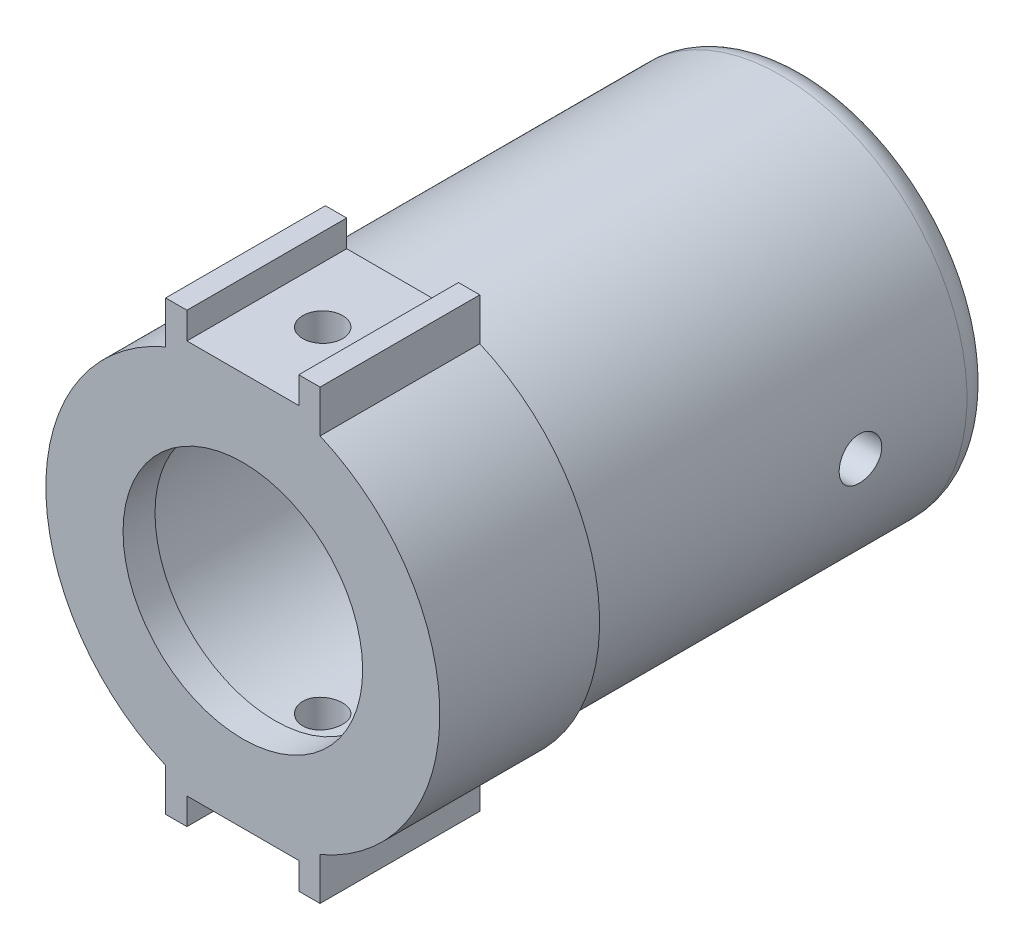
from build123d import *

# Parameters (mm, degrees)
SKETCH10_R              = 7.4
SKETCH10_R_2            = 4.5
BOSS_EXTRUDE3_DEPTH     = 1.2
SKETCH11_R              = 7.4
SKETCH11_R_2            = 5.2
BOSS_EXTRUDE4_DEPTH     = 20
BOSS_EXTRUDE5_DEPTH     = 7
SKETCH12_R              = 0.75
CUT_EXTRUDE1_DEPTH      = 10
CUT_EXTRUDE1_DEPTH_BACK = 11
SKETCH14_W              = 4.2
SKETCH14_H              = 1
CUT_EXTRUDE2_DEPTH      = 6
CUT_EXTRUDE3_REACH      = 29.148
CUT_EXTRUDE3_END_RADIUS = 7.4
CUT_EXTRUDE6_DEPTH      = 1
SKETCH16_R              = 0.8
CUT_EXTRUDE4_DEPTH      = 10
CUT_EXTRUDE4_DEPTH_BACK = 10
SKETCH19_R              = 7.4
SKETCH19_R_2            = 7
CUT_EXTRUDE7_DEPTH      = 15.2
FILLET1_R               = 1


with BuildPart() as part:
    # Sketch10 → Boss-Extrude3 (new body)
    with BuildSketch(Plane.XY):
        Circle(SKETCH10_R)
        Circle(SKETCH10_R_2, mode=Mode.SUBTRACT)
    extrude(amount=BOSS_EXTRUDE3_DEPTH)

    # Sketch11 → Boss-Extrude4 (add)
    with BuildSketch(Plane(origin=(0, 0, 0), x_dir=(-1, 0, 0), z_dir=(0, 0, -1))):
        Circle(SKETCH11_R)
        Circle(SKETCH11_R_2, mode=Mode.SUBTRACT)
    extrude(amount=BOSS_EXTRUDE4_DEPTH)

    # Sketch13 → Boss-Extrude5 (add)
    with BuildSketch(Plane.XY.offset(1.2)):
        with BuildLine():
            ThreePointArc((-2.9, 6.808083431), (0, 7.4), (2.9, 6.808083431))
            Line((2.9, 6.808083431), (2.9, 8.4))
            Line((2.9, 8.4), (-2.9, 8.4))
            Line((-2.9, 8.4), (-2.9, 6.808083431))
        make_face()
        with BuildLine():
            ThreePointArc((2.9, -6.808083431), (0, -7.4), (-2.9, -6.808083431))
            Line((-2.9, -6.808083431), (-2.9, -8.4))
            Line((-2.9, -8.4), (2.9, -8.4))
            Line((2.9, -8.4), (2.9, -6.808083431))
        make_face()
    extrude(amount=-BOSS_EXTRUDE5_DEPTH)

    # Sketch12 → Cut-Extrude1 (cut, two sides)
    with BuildSketch(Plane(origin=(0, 0, 0), x_dir=(1, 0, 0), z_dir=(0, 1, 0))) as cut_extrude1_sk:
        with Locations(Location((0, 1.8, 0), (0, 0, 90))):
            Circle(SKETCH12_R)
    extrude(amount=CUT_EXTRUDE1_DEPTH, mode=Mode.SUBTRACT)
    extrude(cut_extrude1_sk.sketch, amount=-CUT_EXTRUDE1_DEPTH_BACK, mode=Mode.SUBTRACT)

    # Sketch14 → Cut-Extrude2 (cut)
    with BuildSketch(Plane.XY.offset(1.2)):
        with Locations((0, 7.9)):
            Rectangle(SKETCH14_W, SKETCH14_H)
        with Locations((0, -7.9)):
            Rectangle(SKETCH14_W, SKETCH14_H)
    extrude(amount=-CUT_EXTRUDE2_DEPTH, mode=Mode.SUBTRACT)

    # Cut-Extrude3: up to this cylinder (the profile starts outside it)
    cut_extrude3_end = Plane(origin=(0, 0, -5.3), z_dir=(0, 0, -1)) * Cylinder(CUT_EXTRUDE3_END_RADIUS, 74.096, mode=Mode.PRIVATE)
    # Sketch15 → Cut-Extrude3 (cut, up to the surface)
    with BuildSketch(Plane(origin=(0, 8.4, 0), x_dir=(1, 0, 0), z_dir=(0, 1, 0)), mode=Mode.PRIVATE) as cut_extrude3_sk1:
        Polygon((-2.9, 5.8), (-2.9, 4.8), (-2.1, 4.8), (2.1, 4.8), (2.9, 4.8), (2.9, 5.8), align=None)
    cut_extrude3_tool1 = extrude(cut_extrude3_sk1.sketch, amount=-CUT_EXTRUDE3_REACH, mode=Mode.PRIVATE) - cut_extrude3_end
    add(cut_extrude3_tool1.solids().sort_by_distance((0, 8.4, -5.3))[0], mode=Mode.SUBTRACT)

    # Sketch18 → Cut-Extrude6 (cut)
    with BuildSketch(Plane(origin=(0, 0, -5.8), x_dir=(-1, 0, 0), z_dir=(0, 0, -1))):
        with BuildLine():
            Line((-2.9, -6.808083431), (-2.9, -8.4))
            Line((-2.9, -8.4), (2.9, -8.4))
            Line((2.9, -8.4), (2.9, -6.808083431))
            ThreePointArc((2.9, -6.808083431), (0, -7.4), (-2.9, -6.808083431))
        make_face()
    extrude(amount=-CUT_EXTRUDE6_DEPTH, mode=Mode.SUBTRACT)

    # Sketch16 → Cut-Extrude4 (cut, two sides)
    with BuildSketch(Plane(origin=(0, 0, 0), x_dir=(0, 0, -1), z_dir=(1, 0, 0))) as cut_extrude4_sk:
        with Locations(Location((15, 0, 0), (0, 0, 180))):
            Circle(SKETCH16_R)
    extrude(amount=CUT_EXTRUDE4_DEPTH, mode=Mode.SUBTRACT)
    extrude(cut_extrude4_sk.sketch, amount=-CUT_EXTRUDE4_DEPTH_BACK, mode=Mode.SUBTRACT)

    # Sketch19 → Cut-Extrude7 (cut)
    with BuildSketch(Plane(origin=(0, 0, -20), x_dir=(-1, 0, 0), z_dir=(0, 0, -1))):
        Circle(SKETCH19_R)
        Circle(SKETCH19_R_2, mode=Mode.SUBTRACT)
    extrude(amount=-CUT_EXTRUDE7_DEPTH, mode=Mode.SUBTRACT)

    # Fillet1
    fillet1_edges = [part.edges().sort_by_distance(p)[0] for p in [
        (7, 0, -20),
    ]]
    fillet(fillet1_edges, radius=FILLET1_R)


solid = part.part
